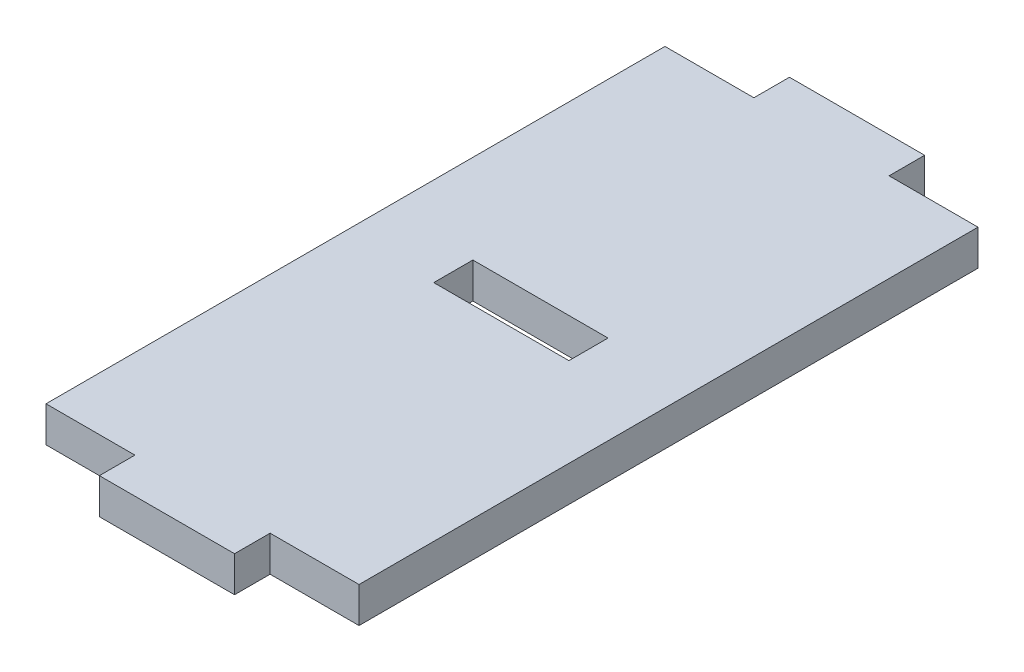
from build123d import *

# Parameters (mm, degrees)
SKETCH_1_W      = 17.6
SKETCH_1_H      = 34.8
SKETCH_1_W_2    = 7.6
SKETCH_1_H_2    = 2.2
SKETCH_1_H_3    = 2
EXTRUDE_1_DEPTH = 2


with BuildPart() as part:
    # 草图1 → 凸台-拉伸1 (new body)
    with BuildSketch(Plane(origin=(0, 0, 0), x_dir=(1, 0, 0), z_dir=(0, 1, 0))):
        with Locations((8.8, 17.4)):
            Rectangle(SKETCH_1_W, SKETCH_1_H)
        with Locations((8.8, 17.9)):
            Rectangle(SKETCH_1_W_2, SKETCH_1_H_2, mode=Mode.SUBTRACT)
        with Locations((8.8, -1)):
            Rectangle(SKETCH_1_W_2, SKETCH_1_H_3)
        with Locations((8.8, 35.8)):
            Rectangle(SKETCH_1_W_2, SKETCH_1_H_3)
    extrude(amount=EXTRUDE_1_DEPTH)


solid = part.part
